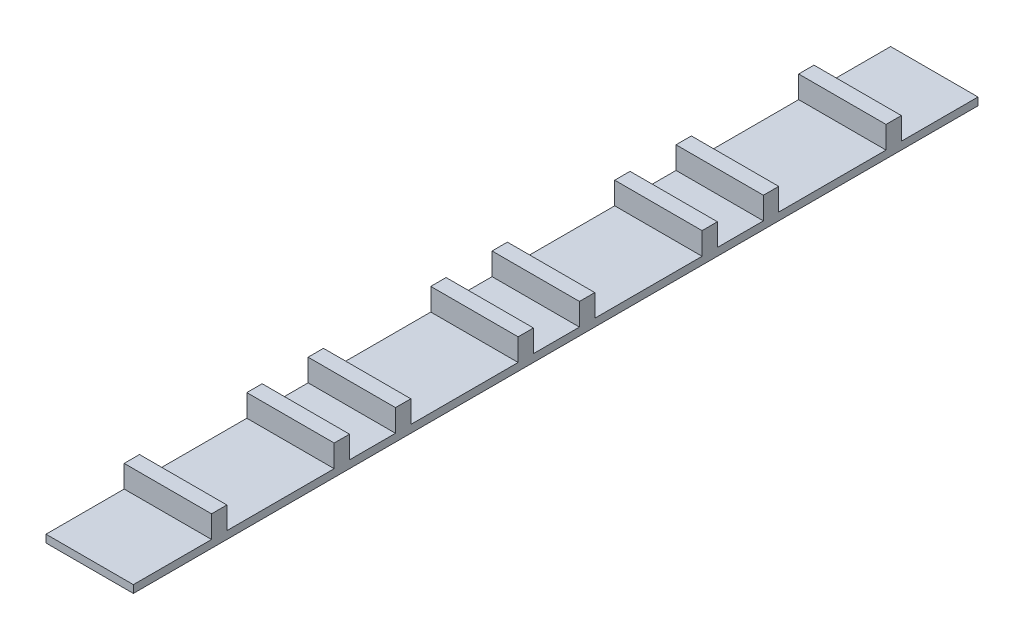
from build123d import *

# Parameters (mm, degrees)
SKETCH1_W           = 14.478
SKETCH1_H           = 1.27
BOSS_EXTRUDE1_DEPTH = 139.954
SKETCH2_W           = 14.478
SKETCH2_H           = 2.54
BOSS_EXTRUDE2_DEPTH = 3.683
LPATTERN1_COUNT     = 4
LPATTERN1_PITCH     = 30.48


with BuildPart() as part:
    # Sketch1 → Boss-Extrude1 (new body)
    with BuildSketch(Plane.XY):
        with Locations((7.239, 0.635)):
            Rectangle(SKETCH1_W, SKETCH1_H)
    extrude(amount=BOSS_EXTRUDE1_DEPTH)

    # Sketch2 → Boss-Extrude2 (add)
    with BuildSketch(Plane(origin=(0, 1.27, 0), x_dir=(1, 0, 0), z_dir=(0, 1, 0))):
        with Locations((7.239, -13.97)):
            Rectangle(SKETCH2_W, SKETCH2_H)
        with Locations((7.239, -34.29)):
            Rectangle(SKETCH2_W, SKETCH2_H)
    boss_extrude2 = extrude(amount=BOSS_EXTRUDE2_DEPTH)

    # LPattern1: Boss-Extrude2 ×4
    with Locations(*[(0, 0, i * LPATTERN1_PITCH) for i in range(1, LPATTERN1_COUNT)]):
        add(boss_extrude2)


solid = part.part
